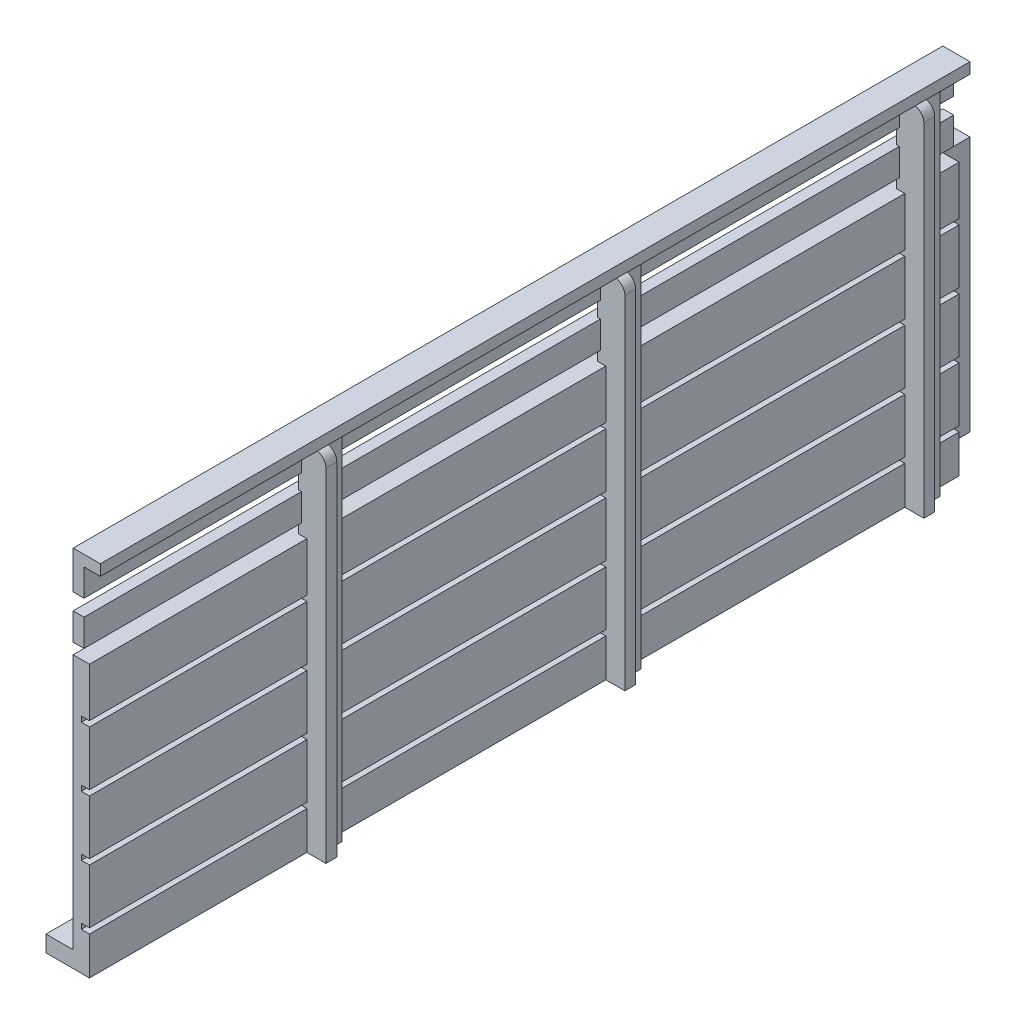
from build123d import *

# Parameters (mm, degrees)
SKETCH1_W           = 160
SKETCH1_H           = 50
BOSS_EXTRUDE1_DEPTH = 3
SKETCH3_W           = 160
SKETCH3_H           = 1
CUT_EXTRUDE1_DEPTH  = 1.5
SKETCH4_W           = 5
SKETCH4_H           = 65
BOSS_EXTRUDE2_DEPTH = 1.5
SKETCH5_W           = 2
SKETCH5_H           = 65
BOSS_EXTRUDE3_DEPTH = 2
FILLET1_R           = 2
SKETCH8_W           = 160
SKETCH8_H           = 5
BOSS_EXTRUDE4_DEPTH = 2
SKETCH6_W           = 5
SKETCH6_H           = 160
BOSS_EXTRUDE5_DEPTH = 2
SKETCH10_W          = 160
SKETCH10_H          = 3
BOSS_EXTRUDE6_DEPTH = 5
SKETCH13_W          = 10
SKETCH13_H          = 47.007429362
BOSS_EXTRUDE7_DEPTH = 5


with BuildPart() as part:
    # Sketch1 → Boss-Extrude1 (new body)
    with BuildSketch(Plane(origin=(0, 0, 0), x_dir=(0, 0, -1), z_dir=(1, 0, 0))):
        Rectangle(SKETCH1_W, SKETCH1_H)
    extrude(amount=BOSS_EXTRUDE1_DEPTH)

    # Sketch3 → Cut-Extrude1 (cut)
    with BuildSketch(Plane(origin=(3, 0, 0), x_dir=(0, 0, -1), z_dir=(1, 0, 0))):
        with Locations((0, -17.5)):
            Rectangle(SKETCH3_W, SKETCH3_H)
        with Locations((0, -6.5)):
            Rectangle(SKETCH3_W, SKETCH3_H)
        with Locations((0, 4.5)):
            Rectangle(SKETCH3_W, SKETCH3_H)
        with Locations((0, 15.5)):
            Rectangle(SKETCH3_W, SKETCH3_H)
    extrude(amount=-CUT_EXTRUDE1_DEPTH, mode=Mode.SUBTRACT)

    # Sketch4 → Boss-Extrude2 (add, symmetric)
    with BuildSketch(Plane(origin=(3, 0, 0), x_dir=(0, 0, -1), z_dir=(1, 0, 0))):
        with Locations((-37.5, 7.5)):
            Rectangle(SKETCH4_W, SKETCH4_H)
        with Locations((17.5, 7.5)):
            Rectangle(SKETCH4_W, SKETCH4_H)
        with Locations((72.5, 7.5)):
            Rectangle(SKETCH4_W, SKETCH4_H)
    extrude(amount=BOSS_EXTRUDE2_DEPTH, both=True)

    # Sketch5 → Boss-Extrude3 (add)
    with BuildSketch(Plane(origin=(4.5, 0, 0), x_dir=(0, 0, -1), z_dir=(1, 0, 0))):
        with Locations((-39, 7.5)):
            Rectangle(SKETCH5_W, SKETCH5_H)
        with Locations((16, 7.5)):
            Rectangle(SKETCH5_W, SKETCH5_H)
        with Locations((71, 7.5)):
            Rectangle(SKETCH5_W, SKETCH5_H)
    extrude(amount=BOSS_EXTRUDE3_DEPTH)

    # Fillet1
    fillet1_edges = [part.edges().sort_by_distance(p)[0] for p in [
        (6.5, 40, -71),
        (6.5, 40, -16),
        (6.5, 40, 39),
    ]]
    fillet(fillet1_edges, radius=FILLET1_R)

    # Sketch8 → Boss-Extrude4 (add)
    with BuildSketch(Plane.ZY):
        with Locations((0, 29.5)):
            Rectangle(SKETCH8_W, SKETCH8_H)
        with Locations((0, 37.5)):
            Rectangle(SKETCH8_W, SKETCH8_H)
    extrude(amount=-BOSS_EXTRUDE4_DEPTH)

    # Sketch6 → Boss-Extrude5 (add)
    with BuildSketch(Plane(origin=(0, 40, 0), x_dir=(1, 0, 0), z_dir=(0, 1, 0))):
        with Locations((2.5, 0)):
            Rectangle(SKETCH6_W, SKETCH6_H)
    extrude(amount=BOSS_EXTRUDE5_DEPTH)

    # Sketch10 → Boss-Extrude6 (add)
    with BuildSketch(Plane.ZY):
        with Locations((0, -23.5)):
            Rectangle(SKETCH10_W, SKETCH10_H)
    extrude(amount=BOSS_EXTRUDE6_DEPTH)

    # Sketch13 → Boss-Extrude7 (add)
    with BuildSketch(Plane.ZY):
        with Locations((-80, 1.496285319)):
            Rectangle(SKETCH13_W, SKETCH13_H)
    extrude(amount=BOSS_EXTRUDE7_DEPTH)


solid = part.part
